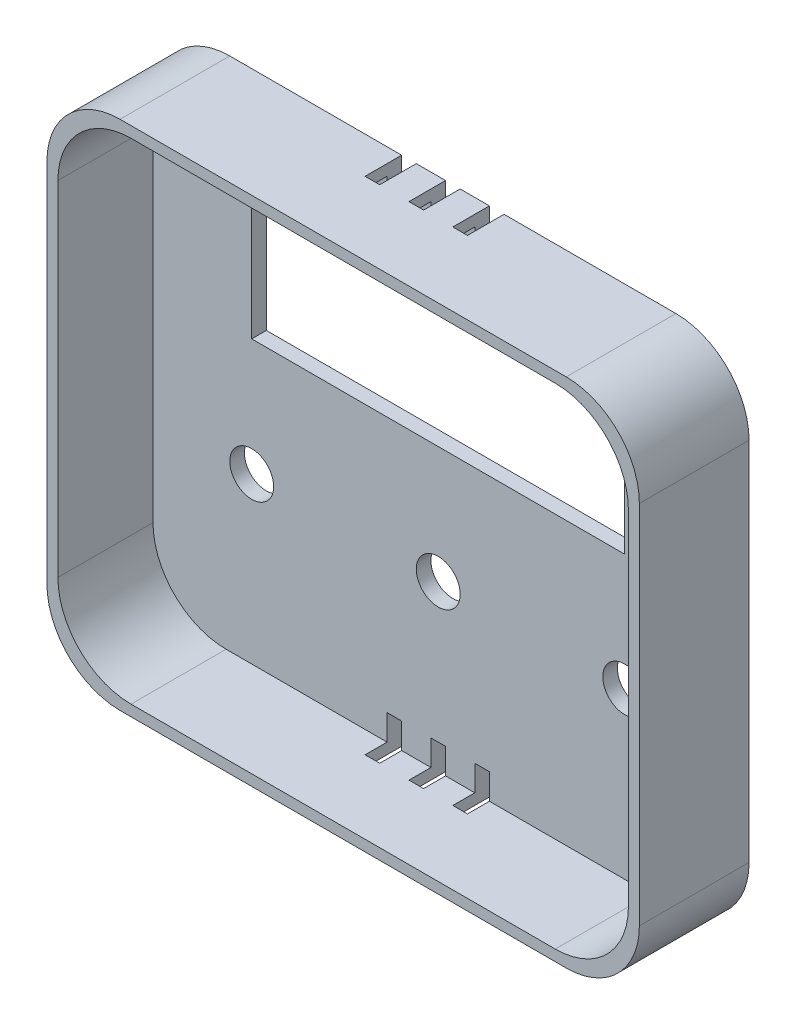
from build123d import *

# Parameters (mm, degrees)
ESQUISSE1_R             = 3
ESQUISSE1_W             = 51
ESQUISSE1_H             = 19.5
BOSS_EXTRU_1_DEPTH      = 2
BOSS_EXTRU_2_DEPTH      = 13
ESQUISSE3_W             = 2
ESQUISSE3_H             = 8.661779492
ESQUISSE3_H_2           = 8.71590367
ESQUISSE3_H_3           = 8.44528278
ESQUISSE3_H_4           = 8.493191711
ENL_V_MAT_EXTRU_1_DEPTH = 5


with BuildPart() as part:
    # Esquisse1 → Boss.-Extru.1 (new body)
    with BuildSketch(Plane.XY):
        with BuildLine():
            Line((-5, 30), (56, 30))
            ThreePointArc((56, 30), (63.071067812, 27.071067812), (66, 20))
            Line((66, 20), (66, -30))
            ThreePointArc((66, -30), (63.071067812, -37.071067812), (56, -40))
            Line((56, -40), (-5, -40))
            ThreePointArc((-5, -40), (-12.071067812, -37.071067812), (-15, -30))
            Line((-15, -30), (-15, 20))
            ThreePointArc((-15, 20), (-12.071067812, 27.071067812), (-5, 30))
        make_face()
        with Locations((0, -16)):
            Circle(ESQUISSE1_R, mode=Mode.SUBTRACT)
        with Locations((25.5, -16)):
            Circle(ESQUISSE1_R, mode=Mode.SUBTRACT)
        with Locations((51, -16)):
            Circle(ESQUISSE1_R, mode=Mode.SUBTRACT)
        with Locations((25.5, 9.75)):
            Rectangle(ESQUISSE1_W, ESQUISSE1_H, mode=Mode.SUBTRACT)
    extrude(amount=BOSS_EXTRU_1_DEPTH)

    # Esquisse2 → Boss.-Extru.2 (add)
    with BuildSketch(Plane.XY.offset(2)):
        with BuildLine():
            Line((-5, 30), (56, 30))
            ThreePointArc((56, 30), (63.071067812, 27.071067812), (66, 20))
            Line((66, 20), (66, -30))
            ThreePointArc((66, -30), (63.071067812, -37.071067812), (56, -40))
            Line((56, -40), (-5, -40))
            ThreePointArc((-5, -40), (-12.071067812, -37.071067812), (-15, -30))
            Line((-15, -30), (-15, 20))
            ThreePointArc((-15, 20), (-12.071067812, 27.071067812), (-5, 30))
        make_face()
        with BuildLine():
            Line((-13.5, 18.5), (-13.5, -28.5))
            ThreePointArc((-13.5, -28.5), (-10.571067812, -35.571067812), (-3.5, -38.5))
            Line((-3.5, -38.5), (54.5, -38.5))
            ThreePointArc((54.5, -38.5), (61.571067812, -35.571067812), (64.5, -28.5))
            Line((64.5, -28.5), (64.5, 18.5))
            ThreePointArc((64.5, 18.5), (61.571067812, 25.571067812), (54.5, 28.5))
            Line((54.5, 28.5), (-3.5, 28.5))
            ThreePointArc((-3.5, 28.5), (-10.571067812, 25.571067812), (-13.5, 18.5))
        make_face(mode=Mode.SUBTRACT)
    extrude(amount=BOSS_EXTRU_2_DEPTH)

    # Esquisse3 → Enlèv. mat.-Extru.1 (cut)
    with BuildSketch(Plane(origin=(0, 0, 0), x_dir=(-1, 0, 0), z_dir=(0, 0, -1))):
        with Locations((-25.5, 29.330889746)):
            Rectangle(ESQUISSE3_W, ESQUISSE3_H)
        with Locations((-31.5, 29.357951835)):
            Rectangle(ESQUISSE3_W, ESQUISSE3_H_2)
        with Locations((-19.5, 29.22264139)):
            Rectangle(ESQUISSE3_W, ESQUISSE3_H_3)
        with Locations((-25.5, -39.246595856)):
            Rectangle(ESQUISSE3_W, ESQUISSE3_H_4)
        with Locations((-31.5, -39.246595856)):
            Rectangle(ESQUISSE3_W, ESQUISSE3_H_4)
        with Locations((-19.5, -39.246595856)):
            Rectangle(ESQUISSE3_W, ESQUISSE3_H_4)
    extrude(amount=-ENL_V_MAT_EXTRU_1_DEPTH, mode=Mode.SUBTRACT)


solid = part.part
